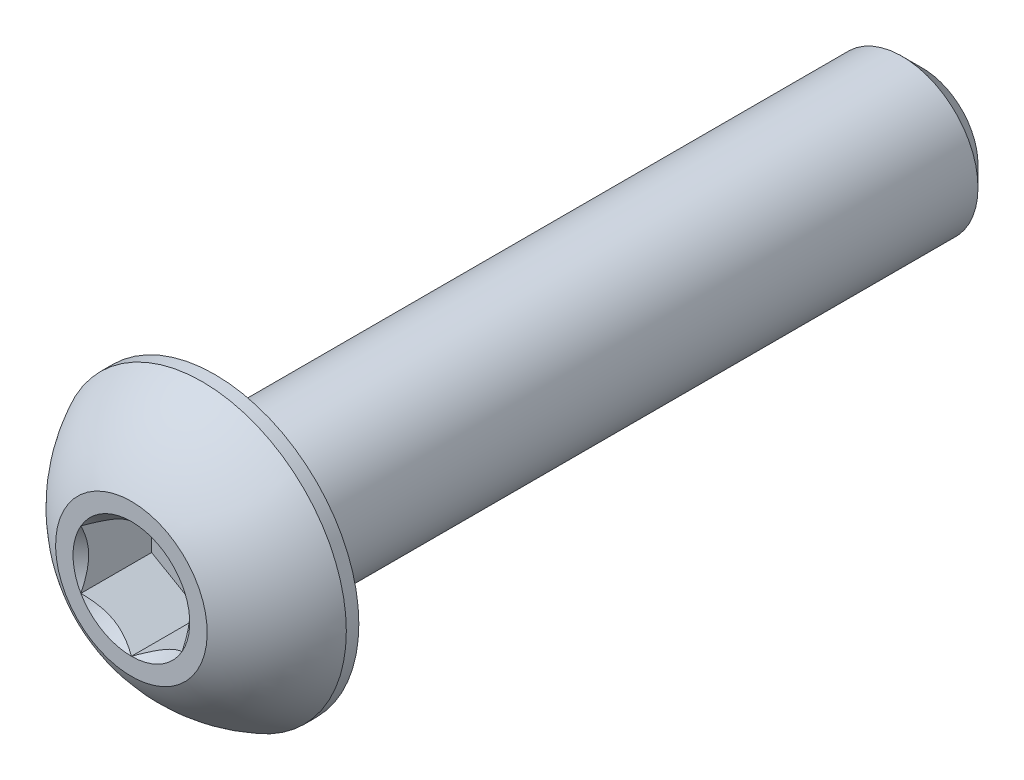
from build123d import *

# Parameters (mm, degrees)
CUT_EXTRUDE1_DEPTH = 1.4


with BuildPart() as part:
    # Sketch2 → Revolve1 (revolve)
    with BuildSketch(Plane(origin=(0, 0, 0), x_dir=(0, 0, -1), z_dir=(1, 0, 0)), mode=Mode.PRIVATE) as revolve1_sk:
        with BuildLine():
            Line((-7.825, 0), (7.825, 0))
            Line((7.825, 0), (7.825, 1.1))
            Line((7.825, 1.1), (7.425, 1.5))
            Line((7.425, 1.5), (-6.175, 1.5))
            Line((-6.175, 1.5), (-6.175, 2.85))
            Line((-6.175, 2.85), (-6.4225, 2.85))
            ThreePointArc((-6.4225, 2.85), (-7.22987489, 2.285251969), (-7.825, 1.5))
            Line((-7.825, 1.5), (-7.825, 0))
        make_face()
    revolve(revolve1_sk.sketch.rotate(Axis((0, 0, 7.825), (0, 0, -1)), 90), axis=Axis((0, 0, 7.825), (0, 0, -1)))

    # Sketch3 → Cut-Extrude1 (cut)
    with BuildSketch(Plane.XY.offset(7.825)):
        Polygon((0, 1.154700538), (-1, 0.577350269), (-1, -0.577350269), (0, -1.154700538), (1, -0.577350269), (1, 0.577350269), align=None)
    extrude(amount=-CUT_EXTRUDE1_DEPTH, mode=Mode.SUBTRACT)

    # Cut-Extrude2 cone 1 section (through the dimple's axis) → Cut-Extrude2 (revolve, cut)
    with BuildSketch(Plane(origin=(0, 0, 7.825), x_dir=(0, -1, 0), z_dir=(1, 0, 0))):
        Polygon((0, 0), (1.154700538, 0), (0, 1.154700538), align=None)
    revolve(axis=Axis((0, 0, 7.825), (0, 0, -1)), mode=Mode.SUBTRACT)


solid = part.part
